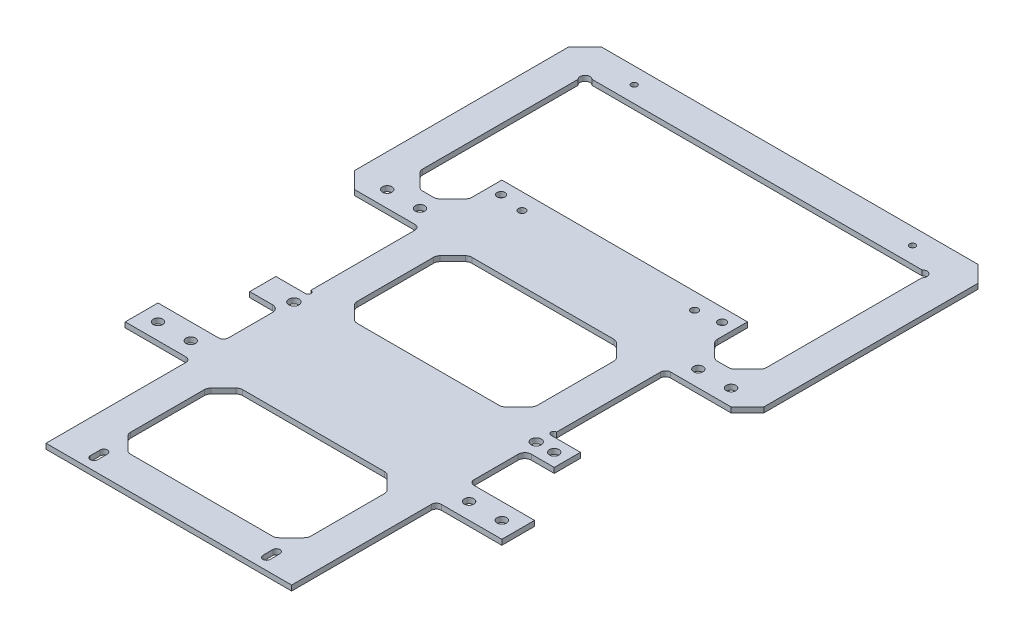
from build123d import *

# Parameters (mm, degrees)
SKETCH1_W                    = 75
SKETCH1_H                    = 139.2
SKETCH1_R                    = 1.1
SKETCH1_W_2                  = 55
SKETCH1_H_2                  = 119.2
BOSS_EXTRUDE1_DEPTH          = 0.8
BOSS_EXTRUDE1_DEPTH_BACK     = 0.8
SKETCH2_W                    = 20
SKETCH2_H                    = 10
BOSS_EXTRUDE2_DEPTH          = 1.6
SKETCH6_W                    = 125
SKETCH6_H                    = 75.4
SKETCH6_W_2                  = 105
SKETCH6_H_2                  = 55.4
BOSS_EXTRUDE4_DEPTH          = 1.6
M2_5_CLEARANCE_HOLE1_D       = 2.9
M2_5_CLEARANCE_HOLE1_DEPTH   = 11.5
FILLET1_R                    = 1.5
CUT_EXTRUDE2_DEPTH           = 10
SKETCH10_W                   = 55
SKETCH10_H                   = 10
BOSS_EXTRUDE5_DEPTH          = 1.6
SKETCH11_W                   = 19
SKETCH11_H                   = 8
SKETCH11_R                   = 1.45
BOSS_EXTRUDE6_DEPTH          = 1.6
SKETCH12_W                   = 55
SKETCH12_H                   = 8
BOSS_EXTRUDE7_DEPTH          = 1.6
FILLET3_R                    = 2
CHAMFER1_SIZE                = 5
SKETCH13_R                   = 1.5
CUT_EXTRUDE3_DEPTH           = 10
SKETCH15_R                   = 1.55
CUT_EXTRUDE4_DEPTH           = 10
CHAMFER2_SIZE                = 5
FILLET4_R                    = 2
SKETCH17_W                   = 58.67264252
SKETCH17_H                   = 24.596391624
SKETCH17_W_2                 = 62.115544984
SKETCH17_H_2                 = 8.350438831
BOSS_EXTRUDE8_DEPTH          = 1.6
SKETCH18_R                   = 0.85
CUT_EXTRUDE5_DEPTH           = 10
M2_CLEARANCE_HOLE1_D         = 2.4
M2_CLEARANCE_HOLE1_DEPTH     = 10
ESQUISSE1_R                  = 0.9
ENL_V_MAT_EXTRU_1_DEPTH      = 10
ENL_V_MAT_EXTRU_1_DEPTH_BACK = 10


with BuildPart() as part:
    # Sketch1 → Boss-Extrude1 (new body, two sides)
    with BuildSketch(Plane(origin=(0, 0, 0), x_dir=(1, 0, 0), z_dir=(0, 1, 0))) as boss_extrude1_sk:
        Rectangle(SKETCH1_W, SKETCH1_H)
        with Locations((-26.35, 64.6)):
            Circle(SKETCH1_R, mode=Mode.SUBTRACT)
        with Locations((26.35, 64.6)):
            Circle(SKETCH1_R, mode=Mode.SUBTRACT)
        with Locations((26.35, -64.6)):
            Circle(SKETCH1_R, mode=Mode.SUBTRACT)
        with Locations((-26.35, -64.6)):
            Circle(SKETCH1_R, mode=Mode.SUBTRACT)
        Rectangle(SKETCH1_W_2, SKETCH1_H_2, mode=Mode.SUBTRACT)
    extrude(amount=BOSS_EXTRUDE1_DEPTH)
    extrude(boss_extrude1_sk.sketch, amount=-BOSS_EXTRUDE1_DEPTH_BACK)

    # Sketch2 → Boss-Extrude2 (add)
    with BuildSketch(Plane(origin=(0, 0.8, 0), x_dir=(1, 0, 0), z_dir=(0, 1, 0))):
        with Locations((47.5, 49.6)):
            Rectangle(SKETCH2_W, SKETCH2_H)
        with Locations((-47.5, 49.6)):
            Rectangle(SKETCH2_W, SKETCH2_H)
        with Locations((47.5, -20.4)):
            Rectangle(SKETCH2_W, SKETCH2_H)
        with Locations((-47.5, -20.4)):
            Rectangle(SKETCH2_W, SKETCH2_H)
    extrude(amount=-BOSS_EXTRUDE2_DEPTH)

    # Sketch6 → Boss-Extrude4 (add)
    with BuildSketch(Plane(origin=(0, 0.8, 0), x_dir=(1, 0, 0), z_dir=(0, 1, 0))):
        with Locations((0, 82.3)):
            Rectangle(SKETCH6_W, SKETCH6_H)
        with Locations((0, 82.3)):
            Rectangle(SKETCH6_W_2, SKETCH6_H_2, mode=Mode.SUBTRACT)
    extrude(amount=-BOSS_EXTRUDE4_DEPTH)

    # M2.5 Clearance Hole1
    with Locations(Plane(origin=(0, 0.8, 0), x_dir=(-1, 0, 0), z_dir=(0, 1, 0))):
        with Locations((-52.5, -49.6), (-52.5, 20.4), (-42.5, -49.6), (-42.5, 20.4)):
            m2_5_clearance_hole1 = Hole(M2_5_CLEARANCE_HOLE1_D / 2, depth=M2_5_CLEARANCE_HOLE1_DEPTH)

    # Mirror1: M2.5 Clearance Hole1 across plane
    add(m2_5_clearance_hole1.mirror(Plane(origin=(0, 0, 0), x_dir=(0, 0, 1), z_dir=(1, 0, 0))), mode=Mode.SUBTRACT)

    # Fillet1
    fillet1_edges = [part.edges().sort_by_distance(p)[0] for p in [
        (37.5, 0, 25.4),
        (37.5, 0, 15.4),
        (-37.5, 0, 15.4),
        (-37.5, 0, 25.4),
        (-37.5, 0, -44.6),
        (37.5, 0, -44.6),
        (27.5, 0, -59.6),
        (-27.5, 0, -59.6),
        (27.5, 0, -54.6),
        (-27.5, 0, -54.6),
    ]]
    fillet(fillet1_edges, radius=FILLET1_R)

    # Sketch9 → Cut-Extrude2 (cut)
    with BuildSketch(Plane(origin=(0, 0.8, 0), x_dir=(1, 0, 0), z_dir=(0, 1, 0))):
        with BuildLine():
            Line((-25.25, -63.1), (-25.25, -66.1))
            ThreePointArc((-25.25, -66.1), (-26.35, -67.2), (-27.45, -66.1))
            Line((-27.45, -66.1), (-27.45, -63.1))
            ThreePointArc((-27.45, -63.1), (-26.35, -62), (-25.25, -63.1))
        make_face()
    cut_extrude2 = extrude(amount=-CUT_EXTRUDE2_DEPTH, mode=Mode.SUBTRACT)

    # Mirror2: Cut-Extrude2 across plane
    add(cut_extrude2.mirror(Plane(origin=(0, 0, 0), x_dir=(0, 0, 1), z_dir=(1, 0, 0))), mode=Mode.SUBTRACT)

    # Sketch10 → Boss-Extrude5 (add)
    with BuildSketch(Plane(origin=(0, 0.8, 0), x_dir=(1, 0, 0), z_dir=(0, 1, 0))):
        with Locations((0, -20.4)):
            Rectangle(SKETCH10_W, SKETCH10_H)
    extrude(amount=-BOSS_EXTRUDE5_DEPTH)

    # Sketch11 → Boss-Extrude6 (add)
    with BuildSketch(Plane(origin=(0, 0.8, 0), x_dir=(1, 0, 0), z_dir=(0, 1, 0))):
        with Locations((-37, 5.6)):
            Rectangle(SKETCH11_W, SKETCH11_H)
        with Locations((37, 5.6)):
            Rectangle(SKETCH11_W, SKETCH11_H)
        with Locations((42.5, 5.6)):
            Circle(SKETCH11_R, mode=Mode.SUBTRACT)
    extrude(amount=-BOSS_EXTRUDE6_DEPTH)

    # Sketch12 → Boss-Extrude7 (add)
    with BuildSketch(Plane(origin=(0, 0.8, 0), x_dir=(1, 0, 0), z_dir=(0, 1, 0))):
        with Locations((0, 5.6)):
            Rectangle(SKETCH12_W, SKETCH12_H)
    extrude(amount=-BOSS_EXTRUDE7_DEPTH)

    # Fillet3
    fillet3_edges = [part.edges().sort_by_distance(p)[0] for p in [
        (37.5, 0, -1.6),
        (-37.5, 0, -1.6),
    ]]
    fillet(fillet3_edges, radius=FILLET3_R)

    # Chamfer1
    chamfer1_edges = [part.edges().sort_by_distance(p)[0] for p in [
        (62.5, 0, -44.6),
        (62.5, 0, -120),
        (-62.5, 0, -120),
        (-62.5, 0, -44.6),
    ]]
    chamfer(chamfer1_edges, length=CHAMFER1_SIZE)

    # Sketch13 → Cut-Extrude3 (cut)
    with BuildSketch(Plane(origin=(0, 0.8, 0), x_dir=(1, 0, 0), z_dir=(0, 1, 0))):
        with Locations((-51.439339828, 108.939339828)):
            Circle(SKETCH13_R)
        with Locations((51.439339828, 108.939339828)):
            Circle(SKETCH13_R)
    extrude(amount=-CUT_EXTRUDE3_DEPTH, mode=Mode.SUBTRACT)

    # Sketch15 → Cut-Extrude4 (cut)
    with BuildSketch(Plane.XZ.offset(0.8)):
        with Locations((37, -5.6)):
            Circle(SKETCH15_R)
    cut_extrude4 = extrude(amount=-CUT_EXTRUDE4_DEPTH, mode=Mode.SUBTRACT)

    # Mirror3: Cut-Extrude4 across plane
    add(cut_extrude4.mirror(Plane(origin=(0, 0, 0), x_dir=(0, 0, 1), z_dir=(1, 0, 0))), mode=Mode.SUBTRACT)

    # Chamfer2
    chamfer2_edges = [part.edges().sort_by_distance(p)[0] for p in [
        (-27.5, 0, 59.6),
        (27.5, 0, 59.6),
        (52.5, 0, -54.6),
        (37.5, 0, -54.6),
        (-37.5, 0, -54.6),
        (-52.5, 0, -54.6),
        (27.5, 0, -44.6),
        (-27.5, 0, -44.6),
        (-27.5, 0, 15.4),
        (27.5, 0, 15.4),
        (27.5, 0, 25.4),
        (-27.5, 0, 25.4),
        (-27.5, 0, -9.6),
        (27.5, 0, -9.6),
        (27.5, 0, -1.6),
        (-27.5, 0, -1.6),
    ]]
    chamfer(chamfer2_edges, length=CHAMFER2_SIZE)

    # Fillet4
    fillet4_edges = [part.edges().sort_by_distance(p)[0] for p in [
        (-27.5, 0, 30.4),
        (-22.5, 0, 25.4),
        (-22.5, 0, -1.6),
        (-27.5, 0, 3.4),
        (-22.5, 0, 15.4),
        (-27.5, 0, 10.4),
        (-22.5, 0, -9.6),
        (-27.5, 0, -14.6),
        (-27.5, 0, -39.6),
        (-22.5, 0, -44.6),
        (37.5, 0, -59.6),
        (42.5, 0, -54.6),
        (47.5, 0, -54.6),
        (52.5, 0, -59.6),
        (22.5, 0, -44.6),
        (27.5, 0, -39.6),
        (22.5, 0, -9.6),
        (27.5, 0, -14.6),
        (22.5, 0, 15.4),
        (27.5, 0, 10.4),
        (27.5, 0, 3.4),
        (22.5, 0, -1.6),
        (27.5, 0, 30.4),
        (22.5, 0, 25.4),
        (22.5, 0, 59.6),
        (27.5, 0, 54.6),
        (-27.5, 0, 54.6),
        (-22.5, 0, 59.6),
        (-52.5, 0, -59.6),
        (-47.5, 0, -54.6),
        (-42.5, 0, -54.6),
        (-37.5, 0, -59.6),
    ]]
    fillet(fillet4_edges, radius=FILLET4_R)

    # Sketch17 → Boss-Extrude8 (add)
    with BuildSketch(Plane(origin=(0, 0.8, 0), x_dir=(1, 0, 0), z_dir=(0, 1, 0))):
        with Locations((0.384318619, -6.570339181)):
            Rectangle(SKETCH17_W, SKETCH17_H)
        with Locations((0.147528901, 56.270374441)):
            Rectangle(SKETCH17_W_2, SKETCH17_H_2)
    extrude(amount=-BOSS_EXTRUDE8_DEPTH)

    # Sketch18 → Cut-Extrude5 (cut)
    with BuildSketch(Plane(origin=(0, 0.8, 0), x_dir=(1, 0, 0), z_dir=(0, 1, 0))):
        with Locations((-37.5, 10.45)):
            Circle(SKETCH18_R)
        with Locations((37.5, 10.45)):
            Circle(SKETCH18_R)
    extrude(amount=-CUT_EXTRUDE5_DEPTH, mode=Mode.SUBTRACT)

    # M2 Clearance Hole1
    with Locations(Plane.XZ.offset(0.8)):
        with Locations((33.75, -65.6), (-33.75, -65.6)):
            Hole(M2_CLEARANCE_HOLE1_D / 2, depth=M2_CLEARANCE_HOLE1_DEPTH)

    # Esquisse1 → Enl_v. mat.-Extru.1 (cut, two sides)
    with BuildSketch(Plane.XZ.offset(0.8)) as enl_v_mat_extru_1_sk:
        with Locations((42.5, -115)):
            Circle(ESQUISSE1_R)
        with Locations((-42.5, -115)):
            Circle(ESQUISSE1_R)
    extrude(amount=ENL_V_MAT_EXTRU_1_DEPTH, mode=Mode.SUBTRACT)
    extrude(enl_v_mat_extru_1_sk.sketch, amount=-ENL_V_MAT_EXTRU_1_DEPTH_BACK, mode=Mode.SUBTRACT)


solid = part.part
